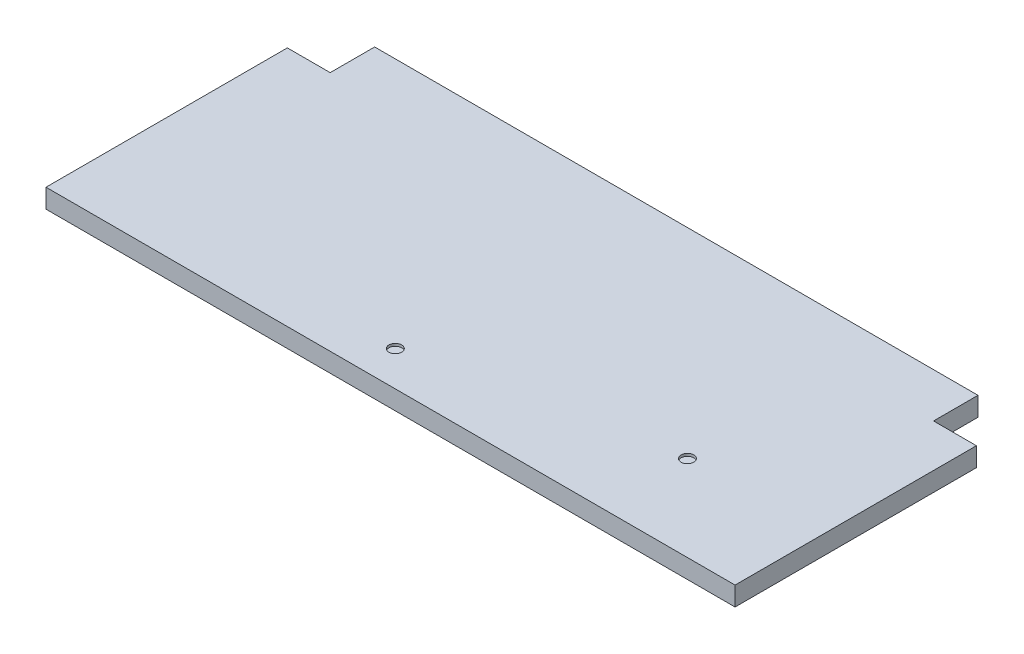
from build123d import *

# Parameters (mm, degrees)
BOSS_EXTRUDE1_DEPTH = 19.05
SKETCH2_R           = 6.35
CUT_EXTRUDE1_DEPTH  = 2.54
SKETCH3_R           = 6.35
CUT_EXTRUDE2_DEPTH  = 2.54


with BuildPart() as part:
    # Sketch1 → Boss-Extrude1 (new body)
    with BuildSketch(Plane(origin=(0, 0, 0), x_dir=(1, 0, 0), z_dir=(0, 1, 0))):
        Polygon((0, 0), (688.975, 0), (688.975, 241.3), (646.1125, 241.3), (646.1125, 285.75), (42.8625, 285.75), (42.8625, 241.3), (0, 241.3), align=None)
    extrude(amount=BOSS_EXTRUDE1_DEPTH)

    # Sketch2 → Cut-Extrude1 (cut)
    with BuildSketch(Plane(origin=(0, 19.05, 0), x_dir=(1, 0, 0), z_dir=(0, 1, 0))):
        with Locations((555.625, 85.725)):
            Circle(SKETCH2_R)
    extrude(amount=-CUT_EXTRUDE1_DEPTH, mode=Mode.SUBTRACT)

    # Sketch3 → Cut-Extrude2 (cut)
    with BuildSketch(Plane(origin=(0, 19.05, 0), x_dir=(1, 0, 0), z_dir=(0, 1, 0))):
        with Locations((314.325, 34.925)):
            Circle(SKETCH3_R)
    extrude(amount=-CUT_EXTRUDE2_DEPTH, mode=Mode.SUBTRACT)


solid = part.part
